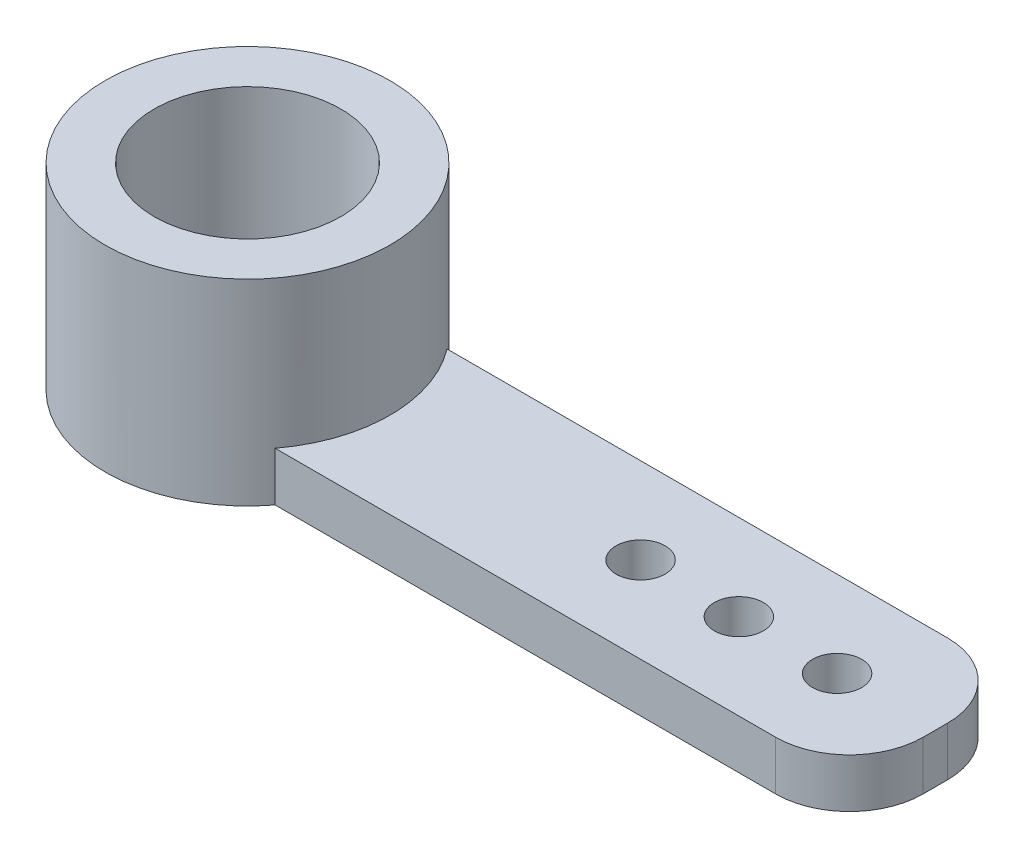
from build123d import *

# Parameters (mm, degrees)
SKETCH_1_R          = 2.9
EXTRUDE_1_DEPTH     = 4
SKETCH_2_W          = 12.628096459
SKETCH_2_H          = 3.5
EXTRUDE_2_DEPTH     = 1
SKETCH_3_R          = 0.5
SKETCH_3_R_2        = 1
CUT_EXTRUDE_1_DEPTH = 5
FILLET_1_R          = 1.5
SKETCH_4_R          = 1.9
CUT_EXTRUDE_2_DEPTH = 3


with BuildPart() as part:
    # 草图1 → 凸台-拉伸1 (new body)
    with BuildSketch(Plane(origin=(0, 0, 0), x_dir=(1, 0, 0), z_dir=(0, 1, 0))):
        Circle(SKETCH_1_R)
    extrude(amount=EXTRUDE_1_DEPTH)

    # 草图2 → 凸台-拉伸2 (add)
    with BuildSketch(Plane(origin=(0, 0, 0), x_dir=(1, 0, 0), z_dir=(0, 1, 0))):
        with Locations((7.685951771, 0)):
            Rectangle(SKETCH_2_W, SKETCH_2_H)
    extrude(amount=EXTRUDE_2_DEPTH)

    # 草图3 → 切除-拉伸1 (cut, through all)
    with BuildSketch(Plane(origin=(0, 0, 0), x_dir=(1, 0, 0), z_dir=(0, 1, 0))):
        with Locations((8, 0)):
            Circle(SKETCH_3_R)
        with Locations((12, 0)):
            Circle(SKETCH_3_R)
        with Locations((10, 0)):
            Circle(SKETCH_3_R)
        Circle(SKETCH_3_R_2)
    extrude(amount=CUT_EXTRUDE_1_DEPTH, mode=Mode.SUBTRACT)

    # 圆角1
    fillet_1_edges = [part.edges().sort_by_distance(p)[0] for p in [
        (14, 0.5, -1.75),
        (14, 0.5, 1.75),
    ]]
    fillet(fillet_1_edges, radius=FILLET_1_R)

    # 草图4 → 切除-拉伸2 (cut)
    with BuildSketch(Plane(origin=(0, 4, 0), x_dir=(1, 0, 0), z_dir=(0, 1, 0))):
        Circle(SKETCH_4_R)
    extrude(amount=-CUT_EXTRUDE_2_DEPTH, mode=Mode.SUBTRACT)


solid = part.part
